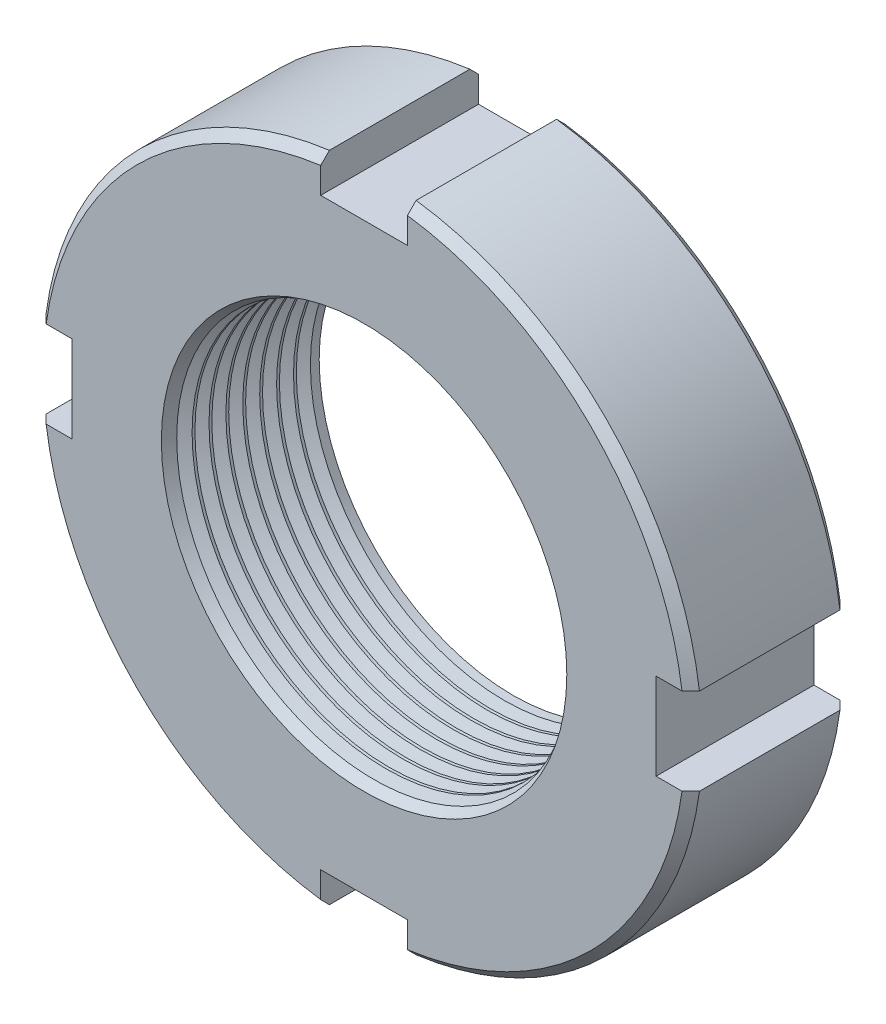
from build123d import *

# Parameters (mm, degrees)
SKETCH2_R               = 19
BASENUT_DEPTH           = 9.1
CHAMFER1_SIZE           = 0.5
SKETCH3_R               = 11.188
HOLE_DEPTH              = 10.1
ENDCHAMFER_SIZE2        = 0.5
ENDCHAMFER_SIZE         = 0.866025404
ENDCHAMFER_EDGE_2_SIZE2 = 0.5
ENDCHAMFER_EDGE_2_SIZE  = 0.866025404
SLOTCUT_DEPTH           = 10.1
SLOTPAT_COUNT           = 4
LPATTERN10_COUNT        = 8
LPATTERN10_PITCH        = 0.9744


with BuildPart() as part:
    # Sketch2 → BaseNut (new body)
    with BuildSketch(Plane.XY):
        Circle(SKETCH2_R)
    extrude(amount=-BASENUT_DEPTH)

    # Chamfer1
    chamfer1_edges = [part.edges().sort_by_distance(p)[0] for p in [
        (-19, 0, 0),
        (-19, 0, -9.1),
    ]]
    chamfer(chamfer1_edges, length=CHAMFER1_SIZE)

    # Sketch3 → Hole (cut, through all)
    with BuildSketch(Plane(origin=(-17.561722019, 31.682666601, 0), x_dir=(1, 0, 0), z_dir=(0, 0, 1))):
        with Locations((17.561722019, -31.682666601)):
            Circle(SKETCH3_R)
    extrude(amount=-HOLE_DEPTH, mode=Mode.SUBTRACT)

    # EndChamfer
    endchamfer_edges = [part.edges().sort_by_distance(p)[0] for p in [
        (-11.188, 0, -9.1),
    ]]
    chamfer(endchamfer_edges, length=ENDCHAMFER_SIZE, length2=ENDCHAMFER_SIZE2)

    # EndChamfer edge 2
    endchamfer_edge_2_edges = [part.edges().sort_by_distance(p)[0] for p in [
        (-11.188, 0, 0),
    ]]
    chamfer(endchamfer_edge_2_edges, length=ENDCHAMFER_EDGE_2_SIZE, length2=ENDCHAMFER_EDGE_2_SIZE2)

    # Sketch4 → SlotCut (cut, through all)
    with BuildSketch(Plane(origin=(-28.84840977, 49.266341409, 0), x_dir=(1, 0, 0), z_dir=(0, 0, 1))):
        with BuildLine():
            Line((26.34840977, -30.431533207), (26.34840977, -32.431533207))
            Line((26.34840977, -32.431533207), (31.34840977, -32.431533207))
            Line((31.34840977, -32.431533207), (31.34840977, -30.431533207))
            ThreePointArc((31.34840977, -30.431533207), (28.84840977, -30.266341409), (26.34840977, -30.431533207))
        make_face()
    slotcut = extrude(amount=-SLOTCUT_DEPTH, mode=Mode.SUBTRACT)

    # SlotPat: SlotCut ×4 about axis
    slotpat_axis = Axis((0, 0, 0), (0, 0, 1))
    for i in range(1, SLOTPAT_COUNT):
        add(slotcut.rotate(slotpat_axis, i * 360 / SLOTPAT_COUNT), mode=Mode.SUBTRACT)

    # Sketch5 → Cut-Revolve10 (revolve, cut)
    with BuildSketch(Plane(origin=(0, 0, 0), x_dir=(1, 0, 0), z_dir=(0, 1, 0))):
        Polygon((10.376, 1.272025404), (10.376, 0.460025404), (11.188, 0.460025404), (11.891212628, 0.866025404), (11.188, 1.272025404), align=None)
    cut_revolve10 = revolve(axis=Axis((0, 0, -37.301805437), (0, 0, 1)), mode=Mode.SUBTRACT)

    # LPattern10: Cut-Revolve10 ×8
    with Locations(*[(0, 0, -i * LPATTERN10_PITCH) for i in range(1, LPATTERN10_COUNT)]):
        add(cut_revolve10, mode=Mode.SUBTRACT)


solid = part.part
